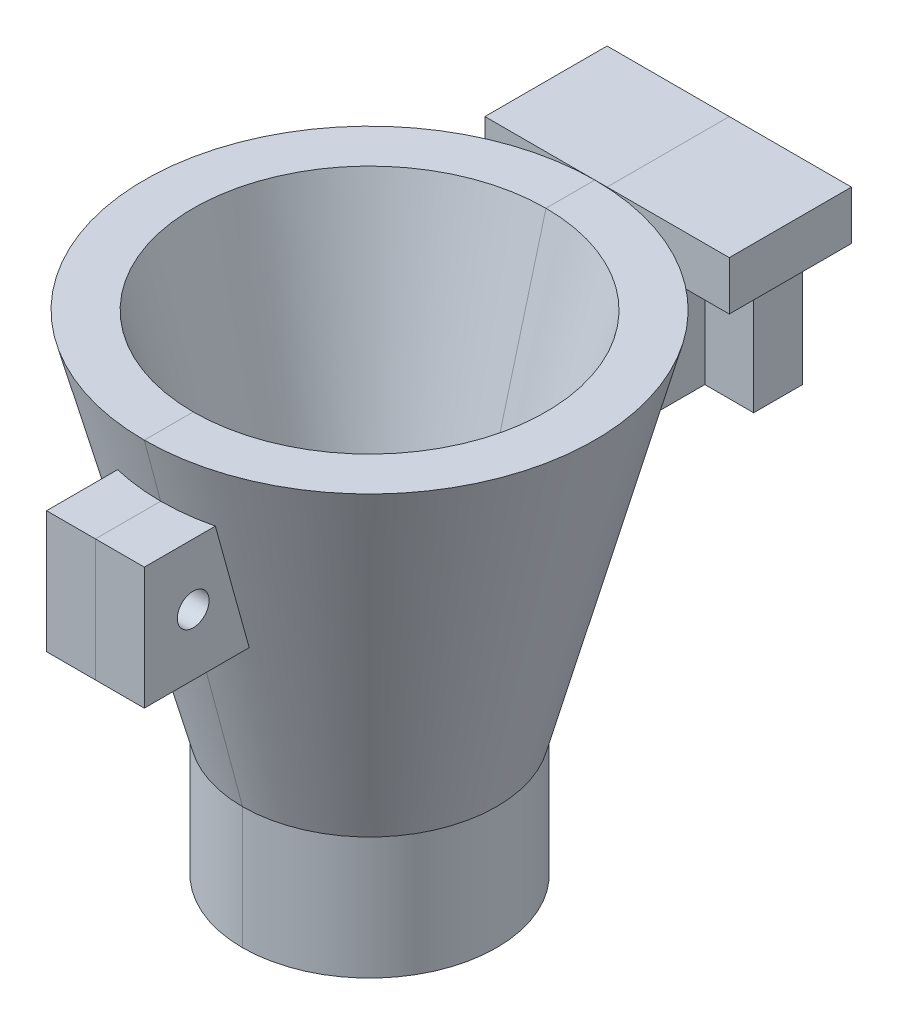
from build123d import *

# Parameters (mm, degrees)
SKETCH13_W          = 34.9924598
SKETCH13_H          = 12.7
SKETCH13_R          = 1.651
BOSS_EXTRUDE1_DEPTH = 5.08
SKETCH14_W          = 20.32
SKETCH14_H          = 5.08
BOSS_EXTRUDE2_DEPTH = 12.7
SKETCH15_W          = 25.4
SKETCH15_H          = 2.54
BOSS_EXTRUDE3_DEPTH = 5.08
SKETCH16_W          = 6.35
SKETCH16_H          = 12.7
CUT_EXTRUDE6_DEPTH  = 29.496864232


with BuildPart() as part:
    # Sketch1 → Revolve1 (revolve)
    with BuildSketch(Plane.XY):
        Polygon((8.128, -12.7), (18.336864232, 25.4), (23.416864232, 25.4), (13.208, -12.7), (13.208, -25.4), (8.128, -25.4), align=None)
    revolve(axis=Axis((0, 0, 0), (0, 1, 0)))

    # Sketch13 → Boss-Extrude1 (add, symmetric)
    with BuildSketch(Plane(origin=(0, 0, 0), x_dir=(0, 0, -1), z_dir=(1, 0, 0))):
        with Locations((-17.350634332, 12.7)):
            Rectangle(SKETCH13_W, SKETCH13_H)
        with Locations((-23.416864232, 12.7)):
            Circle(SKETCH13_R, mode=Mode.SUBTRACT)
    boss_extrude1 = extrude(amount=BOSS_EXTRUDE1_DEPTH, both=True)

    # Mirror1: Boss-Extrude1 across plane
    add(boss_extrude1.mirror(Plane.XY))

    # Sketch14 → Boss-Extrude2 (add)
    with BuildSketch(Plane(origin=(0, 19.05, 0), x_dir=(1, 0, 0), z_dir=(0, 1, 0))):
        with Locations((0, 32.306864232)):
            Rectangle(SKETCH14_W, SKETCH14_H)
    extrude(amount=-BOSS_EXTRUDE2_DEPTH)

    # Sketch15 → Boss-Extrude3 (add)
    with BuildSketch(Plane(origin=(0, 19.05, 0), x_dir=(1, 0, 0), z_dir=(0, 1, 0))):
        Polygon((5.08, 27.226864232), (7.62, 27.226864232), (12.7, 27.226864232), (12.7, 37.386864232), (-12.7, 37.386864232), (-12.7, 27.226864232), (-7.62, 27.226864232), (-5.08, 27.226864232), (-5.08, 29.766864232), (-10.16, 29.766864232), (-10.16, 34.846864232), (10.16, 34.846864232), (10.16, 29.766864232), (5.08, 29.766864232), align=None)
        Polygon((-5.08, 27.226864232), (5.08, 27.226864232), (5.08, 29.766864232), (10.16, 29.766864232), (10.16, 34.846864232), (-10.16, 34.846864232), (-10.16, 29.766864232), (-5.08, 29.766864232), align=None)
        with Locations((0, 25.956864232)):
            Rectangle(SKETCH15_W, SKETCH15_H)
    extrude(amount=BOSS_EXTRUDE3_DEPTH)

    # Sketch16 → Cut-Extrude6 (cut, through all)
    with BuildSketch(Plane(origin=(5.08, 0, 0), x_dir=(0, 0, -1), z_dir=(1, 0, 0))):
        with Locations((-31.671864232, 12.7)):
            Rectangle(SKETCH16_W, SKETCH16_H)
    extrude(amount=-CUT_EXTRUDE6_DEPTH, mode=Mode.SUBTRACT)

    # Sketch17 → Cut-Revolve1 (revolve, cut)
    with BuildSketch(Plane(origin=(0, 0, 0), x_dir=(0, 0, -1), z_dir=(1, 0, 0))):
        Polygon((-18.336864232, 25.4), (0, 25.4), (0, -12.7), (-8.128, -12.7), align=None)
    revolve(axis=Axis((0, 25.4, 0), (0, 1, 0)), mode=Mode.SUBTRACT)


with BuildPart() as body_2:
    # Split1: the piece on the far side of the plane
    add(part.part)
    split(bisect_by=Plane(origin=(0, 0, 0), x_dir=(0, 0, 1), z_dir=(1, 0, 0)), keep=Keep.BOTTOM)


with BuildPart() as part_1:
    add(part.part)

    # Split1
    split(bisect_by=Plane(origin=(0, 0, 0), x_dir=(0, 0, 1), z_dir=(1, 0, 0)), keep=Keep.TOP)


solid = Compound([body_2.part, part_1.part])
